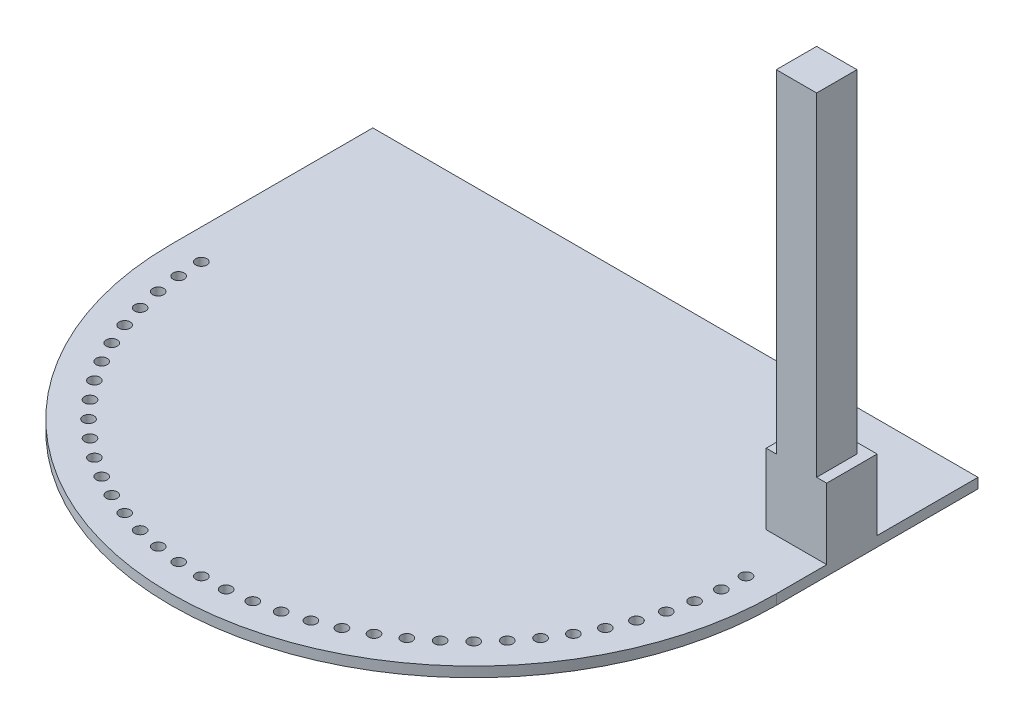
from build123d import *

# Parameters (mm, degrees)
SKETCH1_R           = 2.75
BOSS_EXTRUDE1_DEPTH = 5
BOSS_EXTRUDE2_DEPTH = 35
SKETCH2_3_W         = 20
SKETCH2_3_H         = 20
BOSS_EXTRUDE3_DEPTH = 200


with BuildPart() as part:
    # Sketch1 → Boss-Extrude1 (new body)
    with BuildSketch(Plane(origin=(0, 0, 0), x_dir=(1, 0, 0), z_dir=(0, 1, 0))):
        with BuildLine():
            Line((-150, 0), (-150, 100))
            Line((-150, 100), (150, 100))
            Line((150, 100), (150, 0))
            ThreePointArc((150, 0), (0, -150), (-150, 0))
        make_face()
        with Locations((135, 0)):
            Circle(SKETCH1_R, mode=Mode.SUBTRACT)
        with Locations((134.486284242, -11.766025271)):
            Circle(SKETCH1_R, mode=Mode.SUBTRACT)
        with Locations((132.949046657, -23.442503985)):
            Circle(SKETCH1_R, mode=Mode.SUBTRACT)
        with Locations((130.399986549, -34.940571089)):
            Circle(SKETCH1_R, mode=Mode.SUBTRACT)
        with Locations((126.858503806, -46.172719349)):
            Circle(SKETCH1_R, mode=Mode.SUBTRACT)
        with Locations((122.35155125, -57.053465335)):
            Circle(SKETCH1_R, mode=Mode.SUBTRACT)
        with Locations((116.913429511, -67.5)):
            Circle(SKETCH1_R, mode=Mode.SUBTRACT)
        with Locations((110.585525979, -77.432818907)):
            Circle(SKETCH1_R, mode=Mode.SUBTRACT)
        with Locations((103.415999821, -86.776327308)):
            Circle(SKETCH1_R, mode=Mode.SUBTRACT)
        with Locations((95.45941546, -95.45941546)):
            Circle(SKETCH1_R, mode=Mode.SUBTRACT)
        with Locations((86.776327308, -103.415999821)):
            Circle(SKETCH1_R, mode=Mode.SUBTRACT)
        with Locations((77.432818907, -110.585525979)):
            Circle(SKETCH1_R, mode=Mode.SUBTRACT)
        with Locations((67.5, -116.913429511)):
            Circle(SKETCH1_R, mode=Mode.SUBTRACT)
        with Locations((57.053465335, -122.35155125)):
            Circle(SKETCH1_R, mode=Mode.SUBTRACT)
        with Locations((46.172719349, -126.858503806)):
            Circle(SKETCH1_R, mode=Mode.SUBTRACT)
        with Locations((34.940571089, -130.399986549)):
            Circle(SKETCH1_R, mode=Mode.SUBTRACT)
        with Locations((23.442503985, -132.949046657)):
            Circle(SKETCH1_R, mode=Mode.SUBTRACT)
        with Locations((11.766025271, -134.486284242)):
            Circle(SKETCH1_R, mode=Mode.SUBTRACT)
        with Locations((0, -135)):
            Circle(SKETCH1_R, mode=Mode.SUBTRACT)
        with Locations((-11.766025271, -134.486284242)):
            Circle(SKETCH1_R, mode=Mode.SUBTRACT)
        with Locations((-23.442503985, -132.949046657)):
            Circle(SKETCH1_R, mode=Mode.SUBTRACT)
        with Locations((-34.940571089, -130.399986549)):
            Circle(SKETCH1_R, mode=Mode.SUBTRACT)
        with Locations((-46.172719349, -126.858503806)):
            Circle(SKETCH1_R, mode=Mode.SUBTRACT)
        with Locations((-57.053465335, -122.35155125)):
            Circle(SKETCH1_R, mode=Mode.SUBTRACT)
        with Locations((-67.5, -116.913429511)):
            Circle(SKETCH1_R, mode=Mode.SUBTRACT)
        with Locations((-77.432818907, -110.585525979)):
            Circle(SKETCH1_R, mode=Mode.SUBTRACT)
        with Locations((-86.776327308, -103.415999821)):
            Circle(SKETCH1_R, mode=Mode.SUBTRACT)
        with Locations((-95.45941546, -95.45941546)):
            Circle(SKETCH1_R, mode=Mode.SUBTRACT)
        with Locations((-103.415999821, -86.776327308)):
            Circle(SKETCH1_R, mode=Mode.SUBTRACT)
        with Locations((-110.585525979, -77.432818907)):
            Circle(SKETCH1_R, mode=Mode.SUBTRACT)
        with Locations((-116.913429511, -67.5)):
            Circle(SKETCH1_R, mode=Mode.SUBTRACT)
        with Locations((-122.35155125, -57.053465335)):
            Circle(SKETCH1_R, mode=Mode.SUBTRACT)
        with Locations((-126.858503806, -46.172719349)):
            Circle(SKETCH1_R, mode=Mode.SUBTRACT)
        with Locations((-130.399986549, -34.940571089)):
            Circle(SKETCH1_R, mode=Mode.SUBTRACT)
        with Locations((-132.949046657, -23.442503985)):
            Circle(SKETCH1_R, mode=Mode.SUBTRACT)
        with Locations((-134.486284242, -11.766025271)):
            Circle(SKETCH1_R, mode=Mode.SUBTRACT)
        with Locations((-135, 0)):
            Circle(SKETCH1_R, mode=Mode.SUBTRACT)
    extrude(amount=BOSS_EXTRUDE1_DEPTH)

    # Sketch2 → Boss-Extrude2 (add)
    with BuildSketch(Plane(origin=(0, 5, 0), x_dir=(1, 0, 0), z_dir=(0, 1, 0))):
        Polygon((150, 25), (150, 50), (120, 50), (120, 25), (125, 25), (125, 45), (145, 45), (145, 25), align=None)
    extrude(amount=BOSS_EXTRUDE2_DEPTH)

    # Sketch2_3 → Boss-Extrude3 (add)
    with BuildSketch(Plane(origin=(0, 5, 0), x_dir=(1, 0, 0), z_dir=(0, 1, 0))):
        with Locations((135, 35)):
            Rectangle(SKETCH2_3_W, SKETCH2_3_H)
    extrude(amount=BOSS_EXTRUDE3_DEPTH)


solid = part.part
